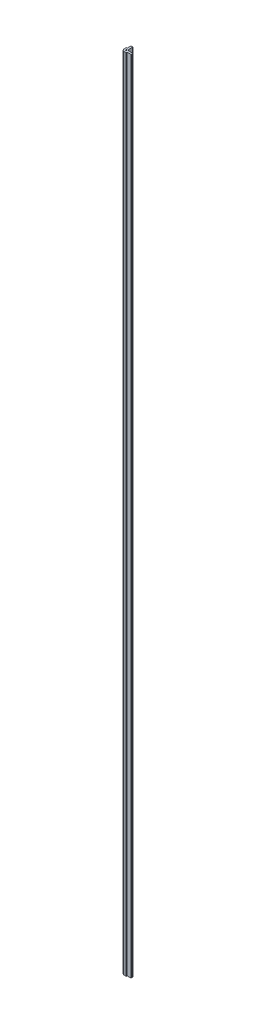
from build123d import *

# Parameters (mm, degrees)
BOSS_EXTRUDE1_DEPTH = 1828.8
THRU_HOLES_D        = 2.794


with BuildPart() as part:
    # Sketch1 → Boss-Extrude1 (new body)
    with BuildSketch(Plane(origin=(0, 0, 0), x_dir=(1, 0, 0), z_dir=(0, 1, 0))):
        with BuildLine():
            Line((-3.048, 13.208), (-3.048, 4.953))
            ThreePointArc((-3.048, 4.953), (-3.085197439, 4.863197439), (-3.175, 4.826))
            Line((-3.175, 4.826), (-4.826, 4.826))
            ThreePointArc((-4.826, 4.826), (-5.005605122, 4.751605122), (-5.08, 4.572))
            Line((-5.08, 4.572), (-5.08, 0))
            ThreePointArc((-5.08, 0), (-3.592102448, -3.592102448), (0, -5.08))
            Line((0, -5.08), (4.572, -5.08))
            ThreePointArc((4.572, -5.08), (4.751605122, -5.005605122), (4.826, -4.826))
            Line((4.826, -4.826), (4.826, -3.175))
            ThreePointArc((4.826, -3.175), (4.863197439, -3.085197439), (4.953, -3.048))
            Line((4.953, -3.048), (13.208, -3.048))
            ThreePointArc((13.208, -3.048), (13.746815367, -2.824815367), (13.97, -2.286))
            Line((13.97, -2.286), (13.97, 0.508))
            ThreePointArc((13.97, 0.508), (13.746815367, 1.046815367), (13.208, 1.27))
            Line((13.208, 1.27), (3.767428831, 1.27))
            ThreePointArc((3.767428831, 1.27), (3.625438515, 1.313394326), (3.531964529, 1.42875))
            ThreePointArc((3.531964529, 1.42875), (2.694076836, 2.694076836), (1.42875, 3.531964529))
            ThreePointArc((1.42875, 3.531964529), (1.313394326, 3.625438515), (1.27, 3.767428831))
            Line((1.27, 3.767428831), (1.27, 13.208))
            ThreePointArc((1.27, 13.208), (1.046815367, 13.746815367), (0.508, 13.97))
            Line((0.508, 13.97), (-2.286, 13.97))
            ThreePointArc((-2.286, 13.97), (-2.824815367, 13.746815367), (-3.048, 13.208))
        make_face()
    extrude(amount=BOSS_EXTRUDE1_DEPTH)

    # THRU HOLES (through all)
    with Locations(Plane(origin=(0, 1828.8, 0), x_dir=(1, 0, 0), z_dir=(0, 1, 0))):
        with Locations((0, 0)):
            Hole(THRU_HOLES_D / 2)


solid = part.part
